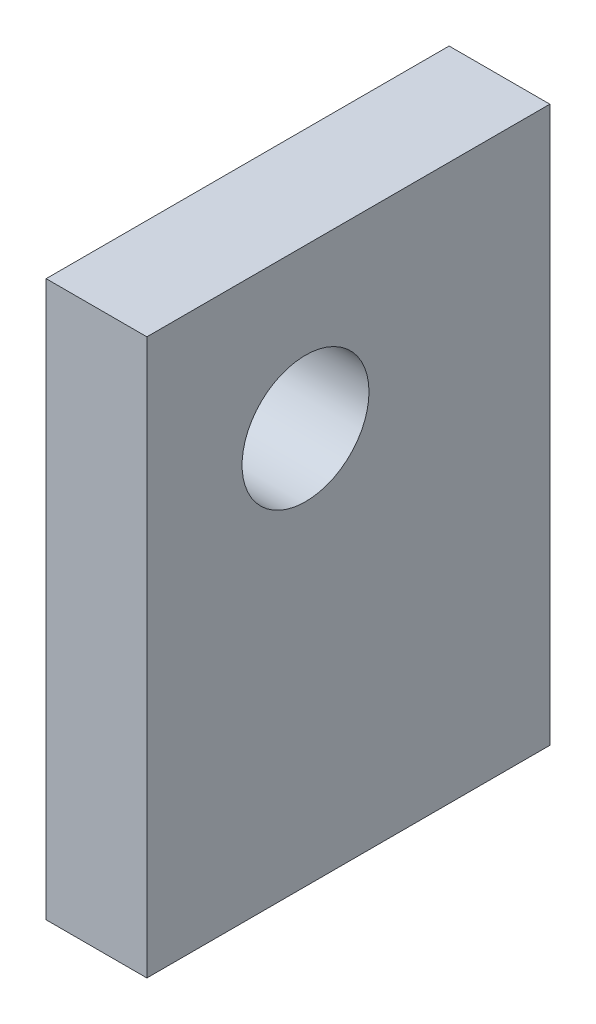
from build123d import *

# Parameters (mm, degrees)
SKETCH2_W           = 25.4
SKETCH2_H           = 101.6
BOSS_EXTRUDE1_DEPTH = 140
SKETCH4_R           = 16
CUT_EXTRUDE2_DEPTH  = 500


with BuildPart() as part:
    # Sketch2 → Boss-Extrude1 (new body)
    with BuildSketch(Plane(origin=(0, 0, 0), x_dir=(1, 0, 0), z_dir=(0, 1, 0))):
        with Locations((12.7, 50.8)):
            Rectangle(SKETCH2_W, SKETCH2_H)
    extrude(amount=BOSS_EXTRUDE1_DEPTH)

    # Sketch4 → Cut-Extrude2 (cut)
    with BuildSketch(Plane(origin=(25.4, 0, 0), x_dir=(0, 0, -1), z_dir=(1, 0, 0))):
        with Locations((40, 100)):
            Circle(SKETCH4_R)
    extrude(amount=-CUT_EXTRUDE2_DEPTH, mode=Mode.SUBTRACT)


solid = part.part
